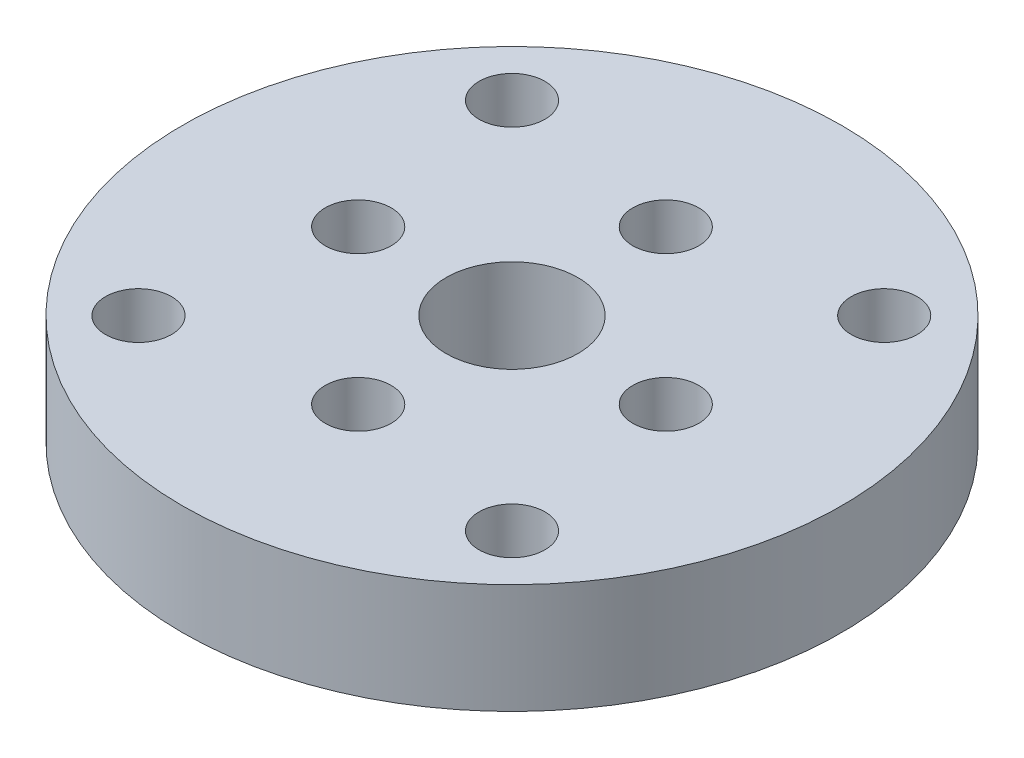
from build123d import *

# Parameters (mm, degrees)
SKETCH1_R           = 15
BOSS_EXTRUDE1_DEPTH = 5
SKETCH3_R           = 1.5
CUT_EXTRUDE2_DEPTH  = 5
SKETCH4_R           = 1.5
CUT_EXTRUDE3_DEPTH  = 5
SKETCH5_R           = 3
CUT_EXTRUDE4_DEPTH  = 10


with BuildPart() as part:
    # Sketch1 → Boss-Extrude1 (new body)
    with BuildSketch(Plane(origin=(0, 0, 0), x_dir=(1, 0, 0), z_dir=(0, 1, 0))):
        Circle(SKETCH1_R)
    extrude(amount=BOSS_EXTRUDE1_DEPTH)

    # Sketch3 → Cut-Extrude2 (cut)
    with BuildSketch(Plane.XZ):
        with Locations((-8.5, 8.5)):
            Circle(SKETCH3_R)
        with Locations((8.485281374, 8.485281374)):
            Circle(SKETCH3_R)
        with Locations((-8.485281374, -8.485281374)):
            Circle(SKETCH3_R)
        with Locations((8.470562748, -8.470562748)):
            Circle(SKETCH3_R)
    extrude(amount=-CUT_EXTRUDE2_DEPTH, mode=Mode.SUBTRACT)

    # Sketch4 → Cut-Extrude3 (cut)
    with BuildSketch(Plane(origin=(0, 5, 0), x_dir=(1, 0, 0), z_dir=(0, 1, 0))):
        with Locations((7, 0)):
            Circle(SKETCH4_R)
        with Locations((0, -7)):
            Circle(SKETCH4_R)
        with Locations((-7, 0)):
            Circle(SKETCH4_R)
        with Locations((0, 7)):
            Circle(SKETCH4_R)
    extrude(amount=-CUT_EXTRUDE3_DEPTH, mode=Mode.SUBTRACT)

    # Sketch5 → Cut-Extrude4 (cut)
    with BuildSketch(Plane(origin=(0, 5, 0), x_dir=(1, 0, 0), z_dir=(0, 1, 0))):
        Circle(SKETCH5_R)
    extrude(amount=-CUT_EXTRUDE4_DEPTH, mode=Mode.SUBTRACT)


solid = part.part
